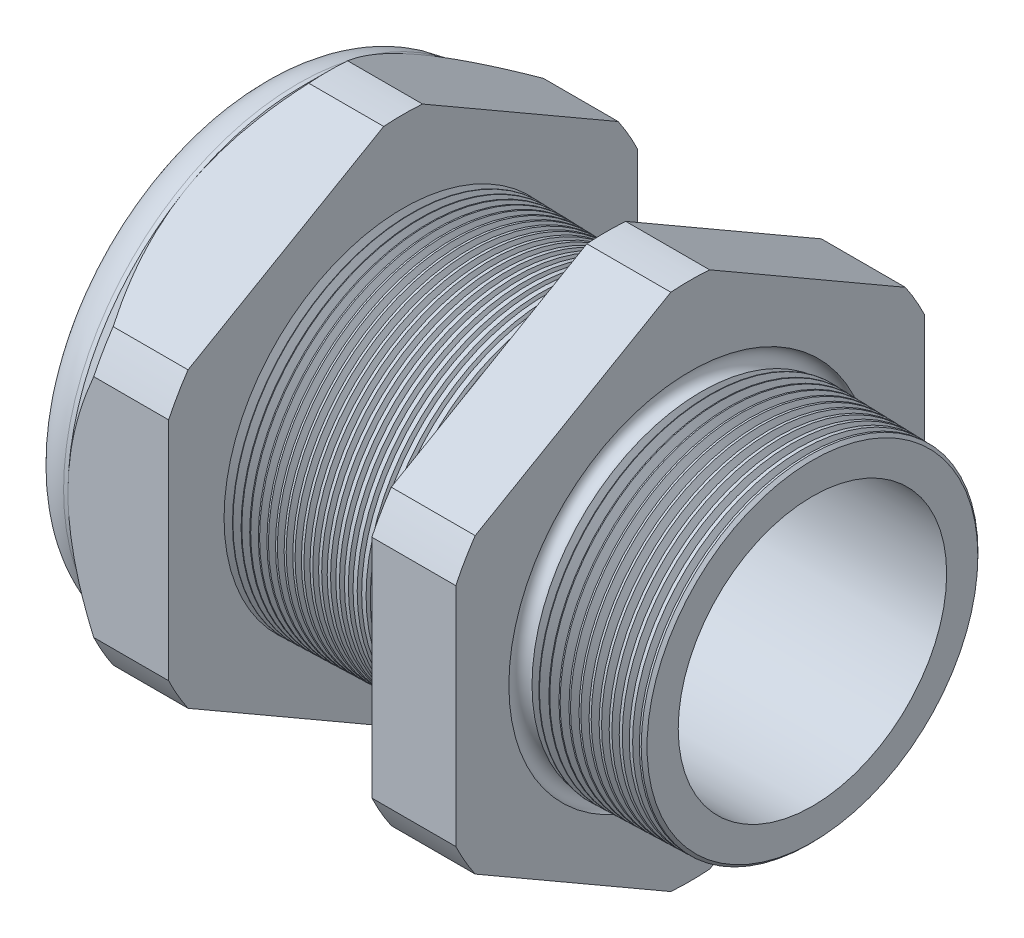
from build123d import *

# Parameters (mm, degrees)
SKETCH12_OUTSIDE_W = 111.534
SKETCH12_OUTSIDE_H = 111.534
CUT_EXTRUDE2_DEPTH = 46.584
FILLET4_R          = 3.81
SKETCH19_OUTSIDE_W = 67.904
SKETCH19_OUTSIDE_H = 72.514
SKETCH19_OUTSIDE_R = 20.955
CUT_EXTRUDE3_DEPTH = 3.99796
CUT_EXTRUDE3_DRAFT = -45
CHAMFER1_SIZE      = 0.260919487
CHAMFER1_SIZE2     = 0.254
SKETCH21_R         = 12.446
PLUG_DEPTH         = 12.7
SKETCH22_R         = 12.192
CUT_EXTRUDE4_DEPTH = 0.508
LPATTERN1_COUNT    = 24
LPATTERN1_PITCH    = 0.762
LPATTERN2_COUNT    = 12
LPATTERN2_PITCH    = 0.889
SKETCH32_R         = 0.889


with BuildPart() as part:
    # Sketch10 → Revolve2 (revolve)
    with BuildSketch(Plane.XY, mode=Mode.PRIVATE) as revolve2_sk:
        Polygon((-46.736, 12.446), (-33.536, 12.446), (3.048, 11.996014245), (3.048, 15.044014245), (-7.874, 15.330016881), (-7.874, 41.91), (-15.374, 41.91), (-15.374, 15.526411292), (-33.536, 16.002), (-33.536, 41.91), (-42.536, 41.91), (-42.536, 20.955), (-46.736, 20.955), align=None)
    revolve(revolve2_sk.sketch.rotate(Axis((0, 0, 0), (-1, 0, 0)), 90), axis=Axis((0, 0, 0), (-1, 0, 0)))  # turned: the seam where the file's is

    # Sketch12 outside → Cut-Extrude2 (cut, through all)
    with BuildSketch(Plane.ZY.offset(42.536)):
        Rectangle(SKETCH12_OUTSIDE_W, SKETCH12_OUTSIDE_H)
        with BuildLine():
            Line((-1.734592832, 23.195282143), (-19.220407168, 13.099842529))
            ThreePointArc((-19.220407168, 13.099842529), (-20.143794193, 11.630025), (-20.955, 10.095439614))
            Line((-20.955, 10.095439614), (-20.955, -10.095439614))
            ThreePointArc((-20.955, -10.095439614), (-20.143794193, -11.630025), (-19.220407168, -13.099842529))
            Line((-19.220407168, -13.099842529), (-1.734592832, -23.195282143))
            ThreePointArc((-1.734592832, -23.195282143), (0, -23.26005), (1.734592832, -23.195282143))
            Line((1.734592832, -23.195282143), (19.220407168, -13.099842529))
            ThreePointArc((19.220407168, -13.099842529), (20.143794193, -11.630025), (20.955, -10.095439614))
            Line((20.955, -10.095439614), (20.955, 10.095439614))
            ThreePointArc((20.955, 10.095439614), (20.143794193, 11.630025), (19.220407168, 13.099842529))
            Line((19.220407168, 13.099842529), (1.734592832, 23.195282143))
            ThreePointArc((1.734592832, 23.195282143), (0, 23.26005), (-1.734592832, 23.195282143))
        make_face(mode=Mode.SUBTRACT)
    extrude(amount=-CUT_EXTRUDE2_DEPTH, mode=Mode.SUBTRACT)

    # Fillet4
    fillet4_edges = [part.edges().sort_by_distance(p)[0] for p in [
        (-46.736, 0, 20.955),
    ]]
    fillet(fillet4_edges, radius=FILLET4_R)


with BuildPart() as cut_extrude3_tool:
    # Sketch19 outside → Cut-Extrude3 (with draft: the straight prism first)
    with BuildSketch(Plane.ZY.offset(42.536)):
        Rectangle(SKETCH19_OUTSIDE_W, SKETCH19_OUTSIDE_H)
        Circle(SKETCH19_OUTSIDE_R, mode=Mode.SUBTRACT)
    extrude(amount=-CUT_EXTRUDE3_DEPTH)
    # Cut-Extrude3: the draft: its side faces are tilted about the plane it starts from
    cut_extrude3_sides = [cut_extrude3_tool.faces().sort_by_distance(p)[0] for p in [
        (-40.53702, -36.257, 0),
        (-40.53702, 0, 33.952),
        (-40.53702, 36.257, 0),
        (-40.53702, 0, -33.952),
        (-40.53702, 0, -20.955),
    ]]
    draft(cut_extrude3_sides, Plane.ZY.offset(42.536), CUT_EXTRUDE3_DRAFT)


with BuildPart() as part_1:
    add(part.part)

    # Cut-Extrude3: cut by cut_extrude3_tool
    add(cut_extrude3_tool.part, mode=Mode.SUBTRACT)

    # Chamfer1
    chamfer1_edges = [part_1.edges().sort_by_distance(p)[0] for p in [
        (3.048, 0, 15.044014245),
    ]]
    chamfer1_side = [part_1.faces().sort_by_distance(p)[0] for p in [
        (3.048, 0, 12.421523225),
    ]]
    chamfer(chamfer1_edges, length=CHAMFER1_SIZE, length2=CHAMFER1_SIZE2, reference=chamfer1_side[0])

    # Sketch29 → Cut-Revolve1 (revolve, cut)
    with BuildSketch(Plane.XY, mode=Mode.PRIVATE) as cut_revolve1_sk:
        Polygon((-33.536, 16.002), (-32.803016419, 15.982806149), (-33.186130572, 15.357620673), align=None)
    cut_revolve1 = revolve(cut_revolve1_sk.sketch.rotate(Axis((0, 0, 0), (-1, 0, 0)), 90), axis=Axis((0, 0, 0), (-1, 0, 0)), mode=Mode.SUBTRACT)  # turned: the seam where the file's is

    # LPattern1: Cut-Revolve1 ×24
    with Locations(*[(i * LPATTERN1_PITCH, 0, 0) for i in range(1, LPATTERN1_COUNT)]):
        add(cut_revolve1, mode=Mode.SUBTRACT)

    # Sketch30 → Cut-Revolve2 (revolve, cut)
    with BuildSketch(Plane.XY, mode=Mode.PRIVATE) as cut_revolve2_sk:
        Polygon((-7.874, 15.330016881), (-6.994419703, 15.30698426), (-7.454156686, 14.556761689), align=None)
    cut_revolve2 = revolve(cut_revolve2_sk.sketch.rotate(Axis((0, 0, 0), (-1, 0, 0)), 270), axis=Axis((0, 0, 0), (-1, 0, 0)), mode=Mode.SUBTRACT)  # turned: the seam where the file's is

    # LPattern2: Cut-Revolve2 ×12
    with Locations(*[(i * LPATTERN2_PITCH, 0, 0) for i in range(1, LPATTERN2_COUNT)]):
        add(cut_revolve2, mode=Mode.SUBTRACT)

    # Sketch32 → Cut-Revolve3 (revolve, cut)
    with BuildSketch(Plane.XY, mode=Mode.PRIVATE) as cut_revolve3_sk:
        with Locations((-7.747, 15.330016881)):
            Circle(SKETCH32_R)
    revolve(cut_revolve3_sk.sketch.rotate(Axis((0, 0, 0), (-1, 0, 0)), 270), axis=Axis((0, 0, 0), (-1, 0, 0)), mode=Mode.SUBTRACT)  # turned: the seam where the file's is


with BuildPart() as body_2:
    # Sketch21 → plug (new body)
    with BuildSketch(Plane.ZY.offset(46.736)):
        Circle(SKETCH21_R)
    extrude(amount=-PLUG_DEPTH)

    # Sketch22 → Cut-Extrude4 (cut)
    with BuildSketch(Plane.ZY.offset(46.736)):
        Circle(SKETCH22_R)
    extrude(amount=-CUT_EXTRUDE4_DEPTH, mode=Mode.SUBTRACT)


solid = Compound([part_1.part, body_2.part])
